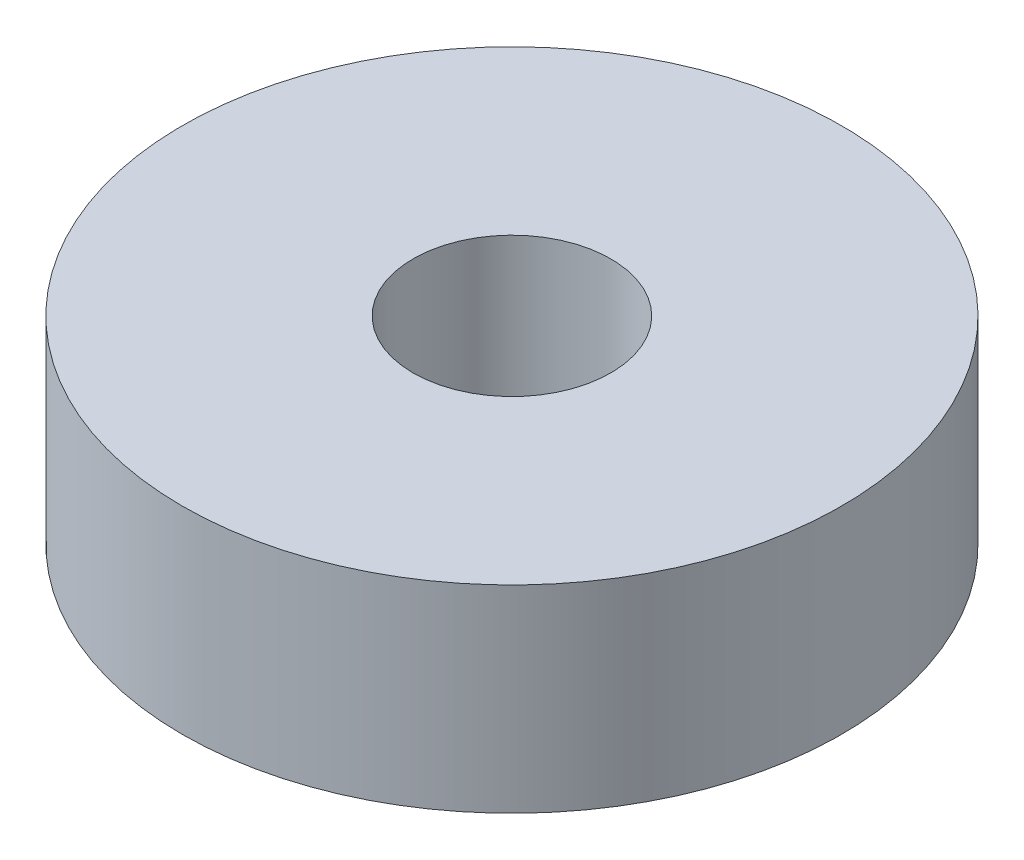
from build123d import *

# Parameters (mm, degrees)
SKETCH1_R           = 10
SKETCH1_R_2         = 3
BOSS_EXTRUDE1_DEPTH = 6


with BuildPart() as part:
    # Sketch1 → Boss-Extrude1 (new body)
    with BuildSketch(Plane(origin=(0, 0, 0), x_dir=(1, 0, 0), z_dir=(0, 1, 0))):
        Circle(SKETCH1_R)
        Circle(SKETCH1_R_2, mode=Mode.SUBTRACT)
    extrude(amount=BOSS_EXTRUDE1_DEPTH)


solid = part.part
